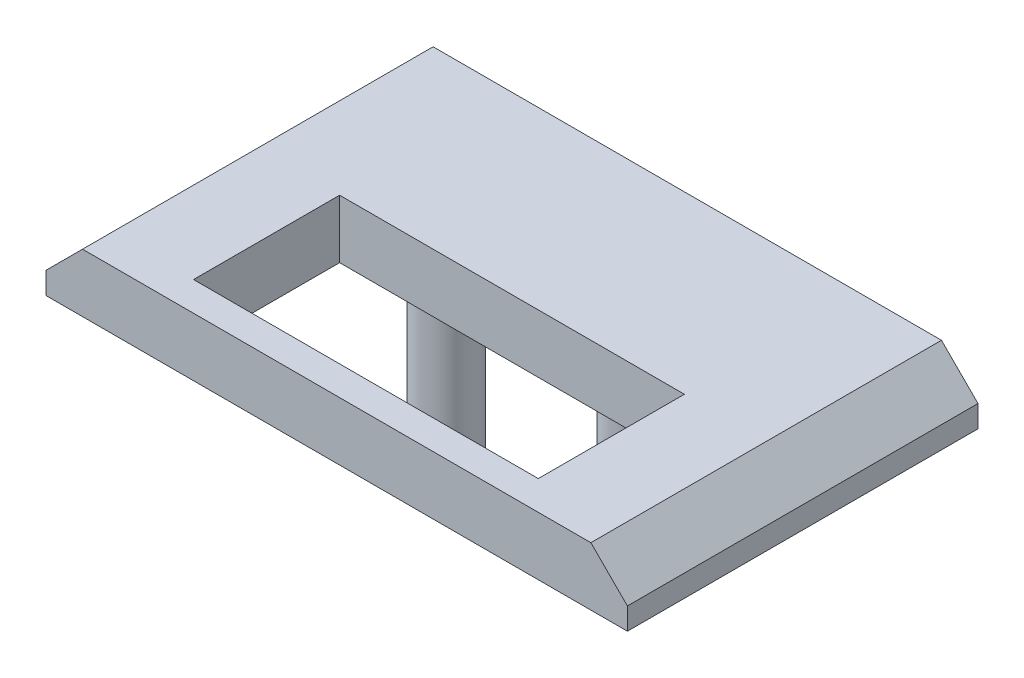
from build123d import *

# Parameters (mm, degrees)
SKETCH1_W           = 19.9
SKETCH1_H           = 12
BOSS_EXTRUDE1_DEPTH = 2
SKETCH2_W           = 11.8
SKETCH2_H           = 5
CUT_EXTRUDE1_DEPTH  = 3
CHAMFER1_SIZE       = 1.25
SKETCH3_R           = 0.95
BOSS_EXTRUDE2_DEPTH = 5.6
CHAMFER2_SIZE       = 0.2


with BuildPart() as part:
    # Sketch1 → Boss-Extrude1 (new body)
    with BuildSketch(Plane(origin=(0, 0, 0), x_dir=(1, 0, 0), z_dir=(0, 1, 0))):
        Rectangle(SKETCH1_W, SKETCH1_H)
    extrude(amount=BOSS_EXTRUDE1_DEPTH)

    # Sketch2 → Cut-Extrude1 (cut, through all)
    with BuildSketch(Plane(origin=(0, 2, 0), x_dir=(1, 0, 0), z_dir=(0, 1, 0))):
        with Locations((0, -2.5)):
            Rectangle(SKETCH2_W, SKETCH2_H)
    extrude(amount=-CUT_EXTRUDE1_DEPTH, mode=Mode.SUBTRACT)

    # Chamfer1
    chamfer1_edges = [part.edges().sort_by_distance(p)[0] for p in [
        (-9.95, 2, 0),
        (9.95, 2, 0),
    ]]
    chamfer(chamfer1_edges, length=CHAMFER1_SIZE)

    # Sketch3 → Boss-Extrude2 (add)
    with BuildSketch(Plane.XZ):
        with Locations((-3.25, -1)):
            Circle(SKETCH3_R)
        with Locations((3.25, -1)):
            Circle(SKETCH3_R)
    extrude(amount=BOSS_EXTRUDE2_DEPTH)

    # Chamfer2
    chamfer2_edges = [part.edges().sort_by_distance(p)[0] for p in [
        (-4.2, -5.6, -1),
        (2.3, -5.6, -1),
    ]]
    chamfer(chamfer2_edges, length=CHAMFER2_SIZE)


solid = part.part
